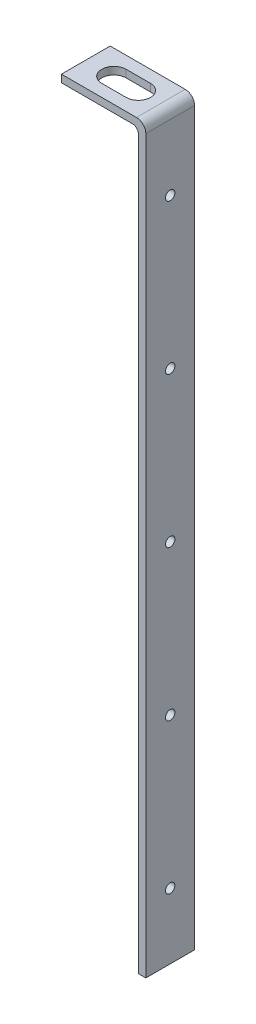
from build123d import *

# Parameters (mm, degrees)
BOSS_EXTRUDE1_DEPTH = 26
SKETCH2_R           = 2.5
CUT_EXTRUDE1_DEPTH  = 46
CUT_EXTRUDE2_DEPTH  = 396
FILLET1_R           = 3
FILLET2_R           = 5


with BuildPart() as part:
    # Sketch1 → Boss-Extrude1 (new body)
    with BuildSketch(Plane.XY):
        Polygon((0, 0), (0, 395), (-45, 395), (-45, 391), (-4, 391), (-4, 0), align=None)
    extrude(amount=BOSS_EXTRUDE1_DEPTH)

    # Sketch2 → Cut-Extrude1 (cut, through all)
    with BuildSketch(Plane(origin=(0, 0, 0), x_dir=(0, 0, -1), z_dir=(1, 0, 0))):
        with Locations((-13, 195)):
            Circle(SKETCH2_R)
        with Locations((-13, 115)):
            Circle(SKETCH2_R)
        with Locations((-13, 35)):
            Circle(SKETCH2_R)
        with Locations((-13, 275)):
            Circle(SKETCH2_R)
        with Locations((-13, 355)):
            Circle(SKETCH2_R)
    extrude(amount=-CUT_EXTRUDE1_DEPTH, mode=Mode.SUBTRACT)

    # Sketch3 → Cut-Extrude2 (cut, through all)
    with BuildSketch(Plane(origin=(0, 395, 0), x_dir=(1, 0, 0), z_dir=(0, 1, 0))):
        with BuildLine():
            Line((-30, -6.5), (-17, -6.5))
            ThreePointArc((-17, -6.5), (-10.5, -13), (-17, -19.5))
            Line((-17, -19.5), (-30, -19.5))
            ThreePointArc((-30, -19.5), (-36.5, -13), (-30, -6.5))
        make_face()
    extrude(amount=-CUT_EXTRUDE2_DEPTH, mode=Mode.SUBTRACT)

    # Fillet1
    fillet1_edges = [part.edges().sort_by_distance(p)[0] for p in [
        (-4, 391, 13),
    ]]
    fillet(fillet1_edges, radius=FILLET1_R)

    # Fillet2
    fillet2_edges = [part.edges().sort_by_distance(p)[0] for p in [
        (0, 395, 13),
    ]]
    fillet(fillet2_edges, radius=FILLET2_R)


solid = part.part
